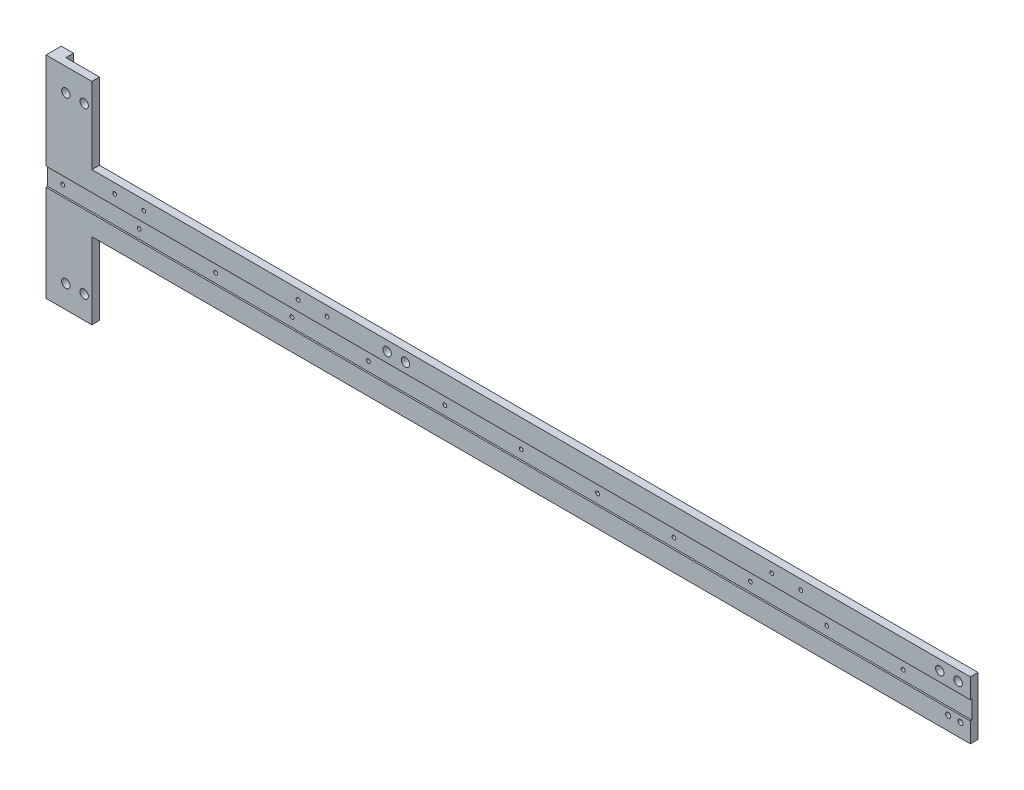
from build123d import *

# Parameters (mm, degrees)
SKETCH_1_W                  = 595
SKETCH_1_H                  = 38
EXTRUDE_1_DEPTH             = 5
HOLE_WIZARD_M3_1_D          = 2.5
PATTERN_LINEAR_1_COUNT      = 12
PATTERN_LINEAR_1_PITCH      = 50
SKETCH_4_W                  = 595
SKETCH_4_H                  = 12
CUT_EXTRUDE_1_DEPTH         = 1
SKETCH_5_W                  = 5
SKETCH_5_H                  = 38
EXTRUDE_2_DEPTH             = 8
HOLE_WIZARD_M4_1_D          = 3.3
HOLE_WIZARD_M4_1_DEPTH      = 6
HOLE_WIZARD_M4_1_TIP        = 0.991420021
EXTRUDE_3_DEPTH             = 10
HOLE_WIZARD_M4_2_D          = 3.3
HOLE_WIZARD_M4_2_DEPTH      = 10.1
HOLE_WIZARD_M4_2_TIP        = 0.991420021
HOLE_WIZARD_M3_2_AT_2_COUNT = 2
HOLE_WIZARD_M3_2_AT_2_PITCH = 19
PATTERN_LINEAR_2_COUNT      = 2
PATTERN_LINEAR_2_PITCH      = 120
PATTERN_LINEAR_3_COUNT      = 2
PATTERN_LINEAR_3_PITCH      = 430
EXTRUDE_4_DEPTH             = 50
EXTRUDE_5_DEPTH             = 50
SKETCH_18_R                 = 2.75
CUT_EXTRUDE_2_DEPTH         = 8
SKETCH_19_R                 = 2.75
CUT_EXTRUDE_3_DEPTH         = 8
SKETCH_20_R                 = 2.75
CUT_EXTRUDE_4_DEPTH         = 8


with BuildPart() as part:
    # 草图1 → 凸台-拉伸1 (new body)
    with BuildSketch(Plane.XY):
        with Locations((297.5, 19)):
            Rectangle(SKETCH_1_W, SKETCH_1_H)
    extrude(amount=EXTRUDE_1_DEPTH)

    # M3 螺纹孔1 (through all)
    with Locations(Plane.XY.offset(5)):
        with Locations((10, 19)):
            hole_wizard_m3_1 = Hole(HOLE_WIZARD_M3_1_D / 2)

    # 阵列(线性)1: M3 螺纹孔1 ×12
    with Locations(*[(i * PATTERN_LINEAR_1_PITCH, 0, 0) for i in range(1, PATTERN_LINEAR_1_COUNT)]):
        add(hole_wizard_m3_1, mode=Mode.SUBTRACT)

    # 草图4 → 切除-拉伸1 (cut)
    with BuildSketch(Plane.XY.offset(5)):
        with Locations((297.5, 19)):
            Rectangle(SKETCH_4_W, SKETCH_4_H)
    extrude(amount=-CUT_EXTRUDE_1_DEPTH, mode=Mode.SUBTRACT)

    # 草图5 → 凸台-拉伸2 (add)
    with BuildSketch(Plane.ZY):
        with Locations((-2.5, 19)):
            Rectangle(SKETCH_5_W, SKETCH_5_H)
    extrude(amount=-EXTRUDE_2_DEPTH)

    # M4 螺纹孔1
    with Locations(Plane.ZY):
        with Locations((0.69552528, 14), (0.69552528, 4)):
            Hole(HOLE_WIZARD_M4_1_D / 2, depth=HOLE_WIZARD_M4_1_DEPTH)
            with Locations((0, 0, -(HOLE_WIZARD_M4_1_DEPTH + HOLE_WIZARD_M4_1_TIP / 2))):  # 118° drill point
                Cone(0, HOLE_WIZARD_M4_1_D / 2, HOLE_WIZARD_M4_1_TIP, mode=Mode.SUBTRACT)

    # 草图8 → 凸台-拉伸3 (add)
    with BuildSketch(Plane(origin=(595, 0, 0), x_dir=(0, 0, -1), z_dir=(1, 0, 0))):
        Polygon((-5, 0), (-5, 13), (-4, 13), (-4, 25), (-5, 25), (-5, 38), (0, 38), (0, 0), align=None)
    extrude(amount=EXTRUDE_3_DEPTH)

    # M4 螺纹孔2
    with Locations(Plane.XY.offset(5)):
        with Locations((598.5, 9.00237217), (590.5, 9.00237217)):
            Hole(HOLE_WIZARD_M4_2_D / 2, depth=HOLE_WIZARD_M4_2_DEPTH)
            with Locations((0, 0, -(HOLE_WIZARD_M4_2_DEPTH + HOLE_WIZARD_M4_2_TIP / 2))):  # 118° drill point
                Cone(0, HOLE_WIZARD_M4_2_D / 2, HOLE_WIZARD_M4_2_TIP, mode=Mode.SUBTRACT)

    # 草图13 → M3 螺纹孔2 (revolve, cut)
    with BuildSketch(Plane(origin=(44.992811473, 31.7, 0), x_dir=(0, 1, 0), z_dir=(1, 0, 0))):
        Polygon((0, 0), (0, 8.251075774), (1.25, 7.5), (1.25, 0), align=None)
    hole_wizard_m3_2 = revolve(axis=Axis((44.992811473, 31.7, -6.35), (0, 0, 1)), mode=Mode.SUBTRACT)

    # M3 螺纹孔2 at 2: M3 螺纹孔2 ×2
    with Locations(*[(i * HOLE_WIZARD_M3_2_AT_2_PITCH, 0, 0) for i in range(1, HOLE_WIZARD_M3_2_AT_2_COUNT)]):
        add(hole_wizard_m3_2, mode=Mode.SUBTRACT)

    # 阵列(线性)2: M3 螺纹孔2 ×2
    with Locations(*[(i * PATTERN_LINEAR_2_PITCH, 0, 0) for i in range(1, PATTERN_LINEAR_2_COUNT)]):
        add(hole_wizard_m3_2, mode=Mode.SUBTRACT)

    # 阵列(线性)2 copy 1 sketch → 阵列(线性)2 copy 1 (revolve, cut)
    with BuildSketch(Plane(origin=(183.992811473, 31.7, 0), x_dir=(0, 1, 0), z_dir=(1, 0, 0))):
        Polygon((0, 0), (0, 8.251075774), (1.25, 7.5), (1.25, 0), align=None)
    revolve(axis=Axis((183.992811473, 31.7, -6.35), (0, 0, 1)), mode=Mode.SUBTRACT)

    # 阵列(线性)3: M3 螺纹孔2 ×2
    with Locations(*[(i * PATTERN_LINEAR_3_PITCH, 0, 0) for i in range(1, PATTERN_LINEAR_3_COUNT)]):
        add(hole_wizard_m3_2, mode=Mode.SUBTRACT)

    # 阵列(线性)3 copy 1 sketch → 阵列(线性)3 copy 1 (revolve, cut)
    with BuildSketch(Plane(origin=(493.992811473, 31.7, 0), x_dir=(0, 1, 0), z_dir=(1, 0, 0))):
        Polygon((0, 0), (0, 8.251075774), (1.25, 7.5), (1.25, 0), align=None)
    revolve(axis=Axis((493.992811473, 31.7, -6.35), (0, 0, 1)), mode=Mode.SUBTRACT)

    # 草图14 → 凸台-拉伸4 (add)
    with BuildSketch(Plane.XZ):
        Polygon((8, -5), (0, -5), (0, 5), (30, 5), (30, 0), (8, 0), align=None)
    extrude(amount=EXTRUDE_4_DEPTH)

    # 草图15 → 凸台-拉伸5 (add)
    with BuildSketch(Plane(origin=(0, 38, 0), x_dir=(1, 0, 0), z_dir=(0, 1, 0))):
        Polygon((0, 5), (0, -5), (30, -5), (30, 0), (8, 0), (8, 5), align=None)
    extrude(amount=EXTRUDE_5_DEPTH)

    # 草图18 → 切除-拉伸2 (cut)
    with BuildSketch(Plane.XY.offset(5)):
        with Locations((25, 73)):
            Circle(SKETCH_18_R)
        with Locations((13, 73)):
            Circle(SKETCH_18_R)
        with Locations((13, -35)):
            Circle(SKETCH_18_R)
        with Locations((25, -35)):
            Circle(SKETCH_18_R)
    extrude(amount=-CUT_EXTRUDE_2_DEPTH, mode=Mode.SUBTRACT)

    # 草图19 → 切除-拉伸3 (cut)
    with BuildSketch(Plane.XY.offset(5)):
        with Locations((585, 31.5)):
            Circle(SKETCH_19_R)
        with Locations((597, 31.5)):
            Circle(SKETCH_19_R)
    extrude(amount=-CUT_EXTRUDE_3_DEPTH, mode=Mode.SUBTRACT)

    # 草图20 → 切除-拉伸4 (cut)
    with BuildSketch(Plane.XY.offset(5)):
        with Locations((235.288610816, 31.5)):
            Circle(SKETCH_20_R)
        with Locations((223.288610816, 31.5)):
            Circle(SKETCH_20_R)
    extrude(amount=-CUT_EXTRUDE_4_DEPTH, mode=Mode.SUBTRACT)


solid = part.part
